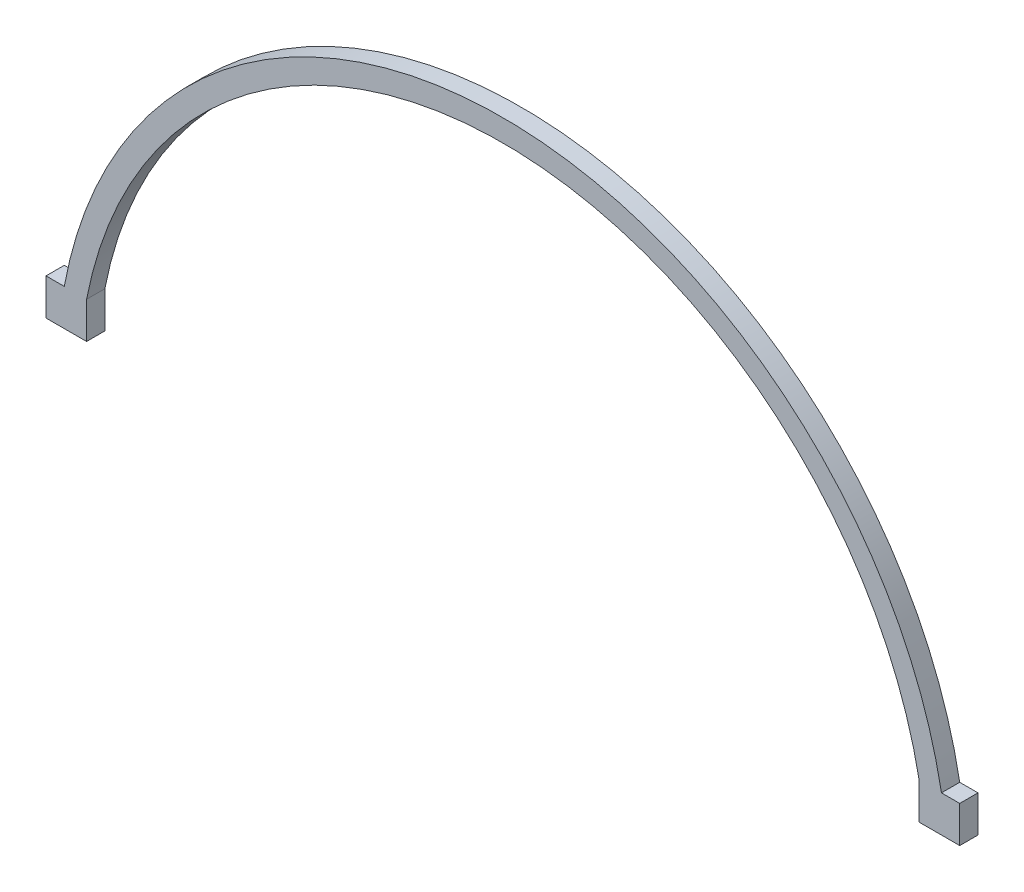
from build123d import *

# Parameters (mm, degrees)
BOSS_EXTRUDE1_DEPTH = 3.175
SKETCH2_W           = 7.051872993
SKETCH2_H           = 3.175
BOSS_EXTRUDE2_DEPTH = 6.35


with BuildPart() as part:
    # Sketch1 → Boss-Extrude1 (new body)
    with BuildSketch(Plane.XY):
        with BuildLine():
            Line((-76.2, 0), (-72.323127007, 0))
            ThreePointArc((-72.323127007, 0), (0, 59.69), (72.323127007, 0))
            Line((72.323127007, 0), (76.2, 0))
            ThreePointArc((76.2, 0), (0, 63.5), (-76.2, 0))
        make_face()
    extrude(amount=BOSS_EXTRUDE1_DEPTH)

    # Sketch2 → Boss-Extrude2 (add)
    with BuildSketch(Plane.XZ):
        with Locations((75.849063504, 1.5875)):
            Rectangle(SKETCH2_W, SKETCH2_H)
        with Locations((-75.849063504, 1.5875)):
            Rectangle(SKETCH2_W, SKETCH2_H)
    extrude(amount=BOSS_EXTRUDE2_DEPTH)


solid = part.part
